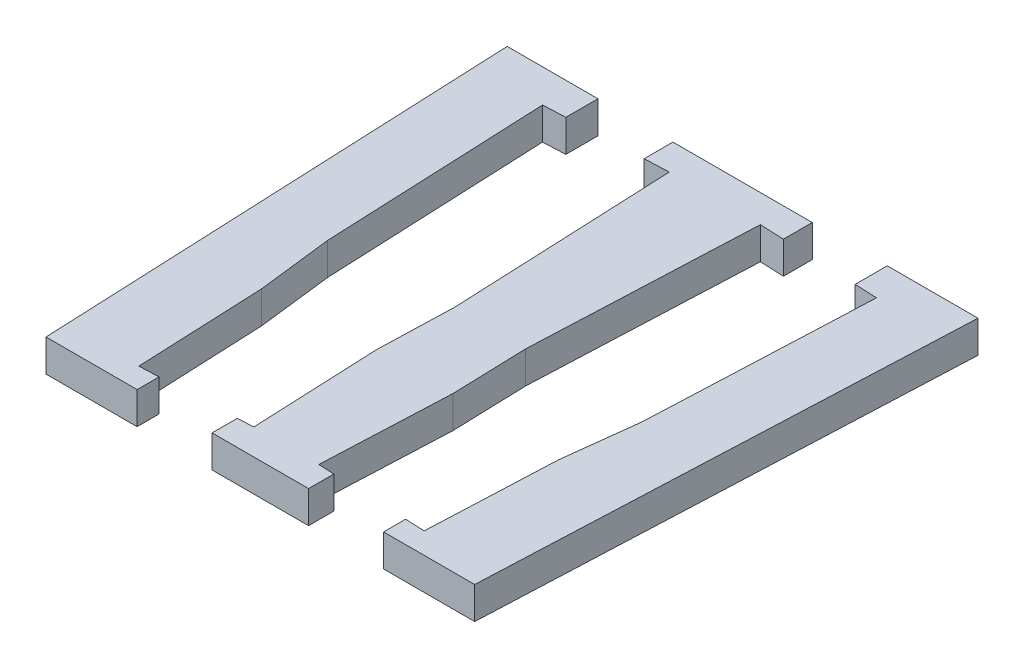
from build123d import *

# Parameters (mm, degrees)
BOSS_EXTRUDE1_DEPTH      = 3
CUT_EXTRUDE1_DEPTH       = 103.427778996
BOSS_EXTRUDE2_DEPTH      = 3
MIRROR4_COPY_1_DEPTH     = 3
CUT_EXTRUDE7_DEPTH       = 103.427778996
CUT_EXTRUDE7_DEPTH_BACK  = 103.427778996
CUT_EXTRUDE8_DEPTH       = 103.427778996
CUT_EXTRUDE8_DEPTH_BACK  = 103.427778996
CUT_EXTRUDE9_DEPTH       = 103.427778996
CUT_EXTRUDE9_DEPTH_BACK  = 103.427778996
CUT_EXTRUDE10_DEPTH      = 103.427778996
CUT_EXTRUDE10_DEPTH_BACK = 103.427778996


with BuildPart() as part:
    # Sketch1 → Boss-Extrude1 (new body)
    with BuildSketch(Plane(origin=(0, 0, 0), x_dir=(1, 0, 0), z_dir=(0, 1, 0))):
        Polygon((-21.964742431, 100), (-20, 55), (0, 55), (0, 100), align=None)
    boss_extrude1 = extrude(amount=BOSS_EXTRUDE1_DEPTH)

    # Sketch2 → Cut-Extrude1 (cut, symmetric)
    with BuildSketch(Plane(origin=(0, 3, 0), x_dir=(1, 0, 0), z_dir=(0, 1, 0))):
        Polygon((-13.837321606, 56.950628888), (-2.508114774, 57.445272741), (-4.252890268, 97.407201604), (-15.582097101, 96.912557752), align=None)
    cut_extrude1 = extrude(amount=CUT_EXTRUDE1_DEPTH, both=True, mode=Mode.SUBTRACT)

    # Sketch6 → Boss-Extrude2 (add)
    with BuildSketch(Plane(origin=(0, 3, 0), x_dir=(1, 0, 0), z_dir=(0, 1, 0))):
        Polygon((-13.837321606, 56.950628888), (-13.31282129, 56.973529067), (-13.836253938, 68.962107726), (-14.666089966, 75.932545098), align=None)
    boss_extrude2 = extrude(amount=-BOSS_EXTRUDE2_DEPTH)

    # Mirror3: Boss-Extrude2 across plane
    add(boss_extrude2.mirror(Plane(origin=(-5.664603416, 0, 0.247321926), x_dir=(0.043619387365336264, 0, 0.9990482215818577), z_dir=(0.9990482215818578, 0, -0.043619387365336264))))

    # Mirror4: Boss-Extrude1, Cut-Extrude1, Boss-Extrude2 across plane
    add(boss_extrude1.mirror(Plane(origin=(0, 0, 0), x_dir=(0, 0, 1), z_dir=(1, 0, 0))))
    add(cut_extrude1.mirror(Plane(origin=(0, 0, 0), x_dir=(0, 0, 1), z_dir=(1, 0, 0))), mode=Mode.SUBTRACT)
    add(boss_extrude2.mirror(Plane(origin=(0, 0, 0), x_dir=(0, 0, 1), z_dir=(1, 0, 0))))

    # Mirror4 copy 1 sketch → Mirror4 copy 1 (add)
    with BuildSketch(Plane(origin=(11.329206833, 3, 0.494643853), x_dir=(0.9961946980917458, 0, 0.08715574274765871), z_dir=(0, 1, 0))):
        Polygon((-13.837321606, 56.950628888), (-13.31282129, 56.973529067), (-13.836253938, 68.962107726), (-14.666089966, 75.932545098), align=None)
    extrude(amount=-MIRROR4_COPY_1_DEPTH)

    # Sketch7 → Cut-Extrude7 (cut, two sides)
    with BuildSketch(Plane(origin=(0, 3, 0), x_dir=(1, 0, 0), z_dir=(0, 1, 0))) as cut_extrude7_sk:
        Polygon((-13.5, 100), (-13.5, 97.003464074), (-6.5, 97.309090675), (-6.5, 100), align=None)
    extrude(amount=CUT_EXTRUDE7_DEPTH, mode=Mode.SUBTRACT)
    extrude(cut_extrude7_sk.sketch, amount=-CUT_EXTRUDE7_DEPTH_BACK, mode=Mode.SUBTRACT)

    # Sketch13 → Cut-Extrude8 (cut, two sides)
    with BuildSketch(Plane(origin=(0, 3, 0), x_dir=(1, 0, 0), z_dir=(0, 1, 0))) as cut_extrude8_sk:
        Polygon((6.5, 97.309090675), (6.5, 100), (13.5, 100), (13.5, 97.003464074), align=None)
    extrude(amount=CUT_EXTRUDE8_DEPTH, mode=Mode.SUBTRACT)
    extrude(cut_extrude8_sk.sketch, amount=-CUT_EXTRUDE8_DEPTH_BACK, mode=Mode.SUBTRACT)

    # Sketch14 → Cut-Extrude9 (cut, two sides)
    with BuildSketch(Plane(origin=(0, 3, 0), x_dir=(1, 0, 0), z_dir=(0, 1, 0))) as cut_extrude9_sk:
        Polygon((-11.5, 57.052678553), (-11.5, 55), (-4.5, 55), (-4.5, 57.358305154), align=None)
    extrude(amount=CUT_EXTRUDE9_DEPTH, mode=Mode.SUBTRACT)
    extrude(cut_extrude9_sk.sketch, amount=-CUT_EXTRUDE9_DEPTH_BACK, mode=Mode.SUBTRACT)


with BuildPart() as cut_extrude9_piece_1:
    # of the separate pieces the step leaves, piece 1, a body of its own (cut_extrude9_pieces)
    add(part.part.solids().sort_by_distance((-4.5, 0, -55))[0])

    # Sketch15 → Cut-Extrude10 (cut, two sides)
    with BuildSketch(Plane(origin=(0, 3, 0), x_dir=(1, 0, 0), z_dir=(0, 1, 0))) as cut_extrude10_sk:
        Polygon((4.5, 57.358305154), (4.5, 55), (11.5, 55), (11.5, 57.052678553), align=None)
    extrude(amount=CUT_EXTRUDE10_DEPTH, mode=Mode.SUBTRACT)
    extrude(cut_extrude10_sk.sketch, amount=-CUT_EXTRUDE10_DEPTH_BACK, mode=Mode.SUBTRACT)


with BuildPart() as cut_extrude9_piece_2:
    # of the separate pieces the step leaves, piece 2, a body of its own (cut_extrude9_pieces)
    add(part.part.solids().sort_by_distance((-21.964742431, 0, -100))[0])


with BuildPart() as cut_extrude10_piece_1:
    # of the separate pieces the step leaves, piece 1, a body of its own (cut_extrude10_pieces)
    add(cut_extrude9_piece_1.part.solids().sort_by_distance((-4.5, 0, -55))[0])


with BuildPart() as cut_extrude10_piece_2:
    # of the separate pieces the step leaves, piece 2, a body of its own (cut_extrude10_pieces)
    add(cut_extrude9_piece_1.part.solids().sort_by_distance((11.5, 0, -55))[0])


solid = Compound([cut_extrude9_piece_2.part, cut_extrude10_piece_1.part, cut_extrude10_piece_2.part])
